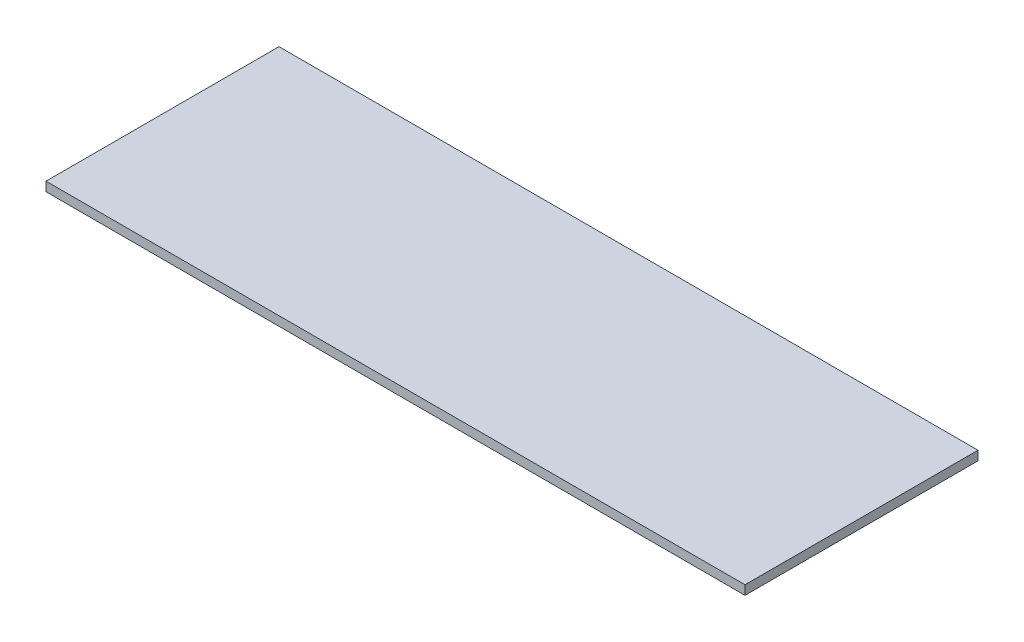
from build123d import *

# Parameters (mm, degrees)
SKETCH1_W           = 76.2
SKETCH1_H           = 25.4
BOSS_EXTRUDE1_DEPTH = 1


with BuildPart() as part:
    # Sketch1 → Boss-Extrude1 (new body)
    with BuildSketch(Plane(origin=(0, 0, 0), x_dir=(1, 0, 0), z_dir=(0, 1, 0))):
        Rectangle(SKETCH1_W, SKETCH1_H)
    extrude(amount=BOSS_EXTRUDE1_DEPTH)


solid = part.part
